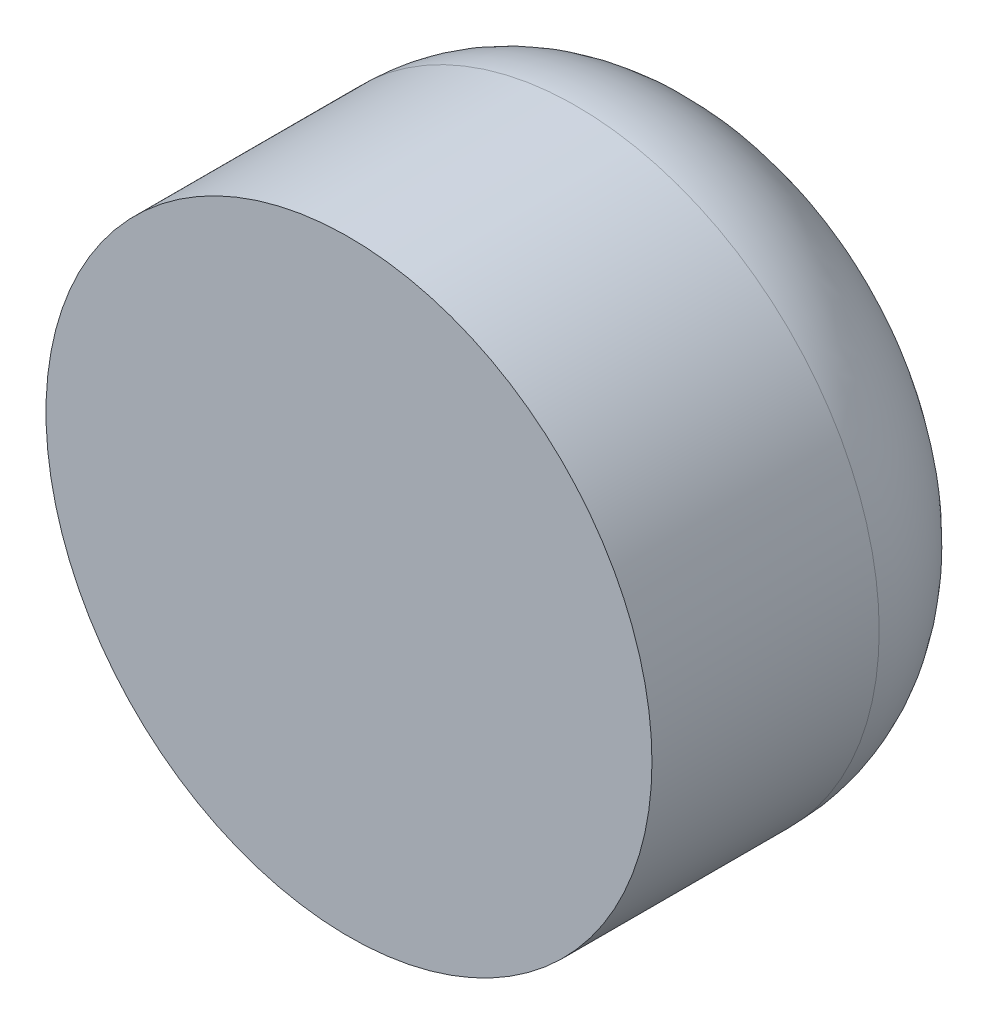
from build123d import *

# Parameters (mm, degrees)
SKETCH2_R           = 4
BOSS_EXTRUDE1_DEPTH = 5
FILLET2_R           = 2


with BuildPart() as part:
    # Sketch2 → Boss-Extrude1 (new body)
    with BuildSketch(Plane.XY):
        Circle(SKETCH2_R)
    extrude(amount=BOSS_EXTRUDE1_DEPTH)

    # Fillet2
    fillet2_edges = [part.edges().sort_by_distance(p)[0] for p in [
        (-4, 0, 0),
    ]]
    fillet(fillet2_edges, radius=FILLET2_R)


solid = part.part
